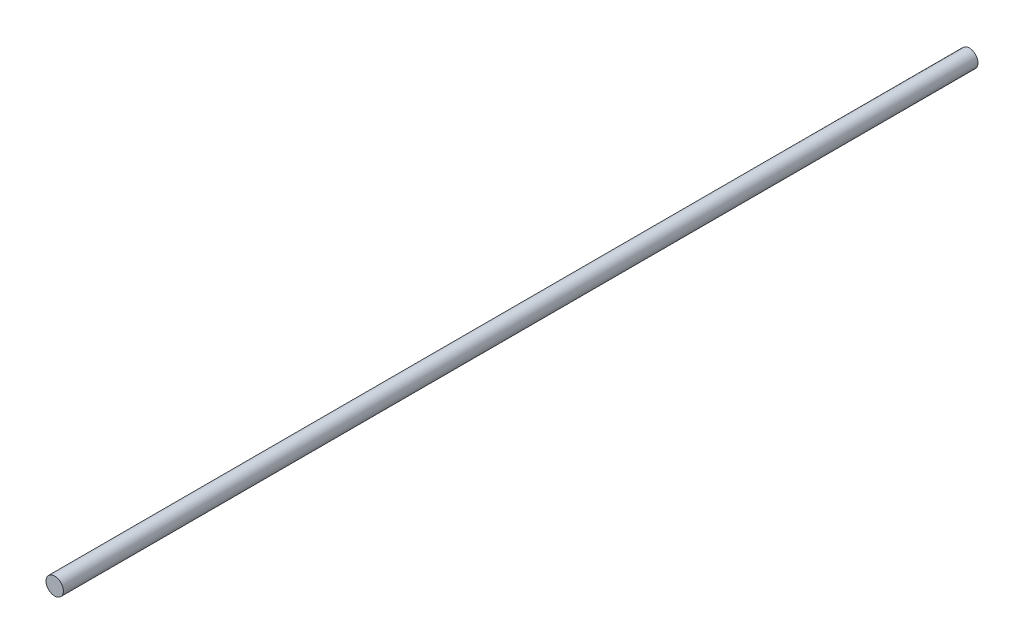
from build123d import *

# Parameters (mm, degrees)
ESQUISSE1_R        = 1.9
BOSS_EXTRU_1_DEPTH = 200


with BuildPart() as part:
    # Esquisse1 → Boss.-Extru.1 (new body)
    with BuildSketch(Plane.XY):
        Circle(ESQUISSE1_R)
    extrude(amount=BOSS_EXTRU_1_DEPTH)


solid = part.part
